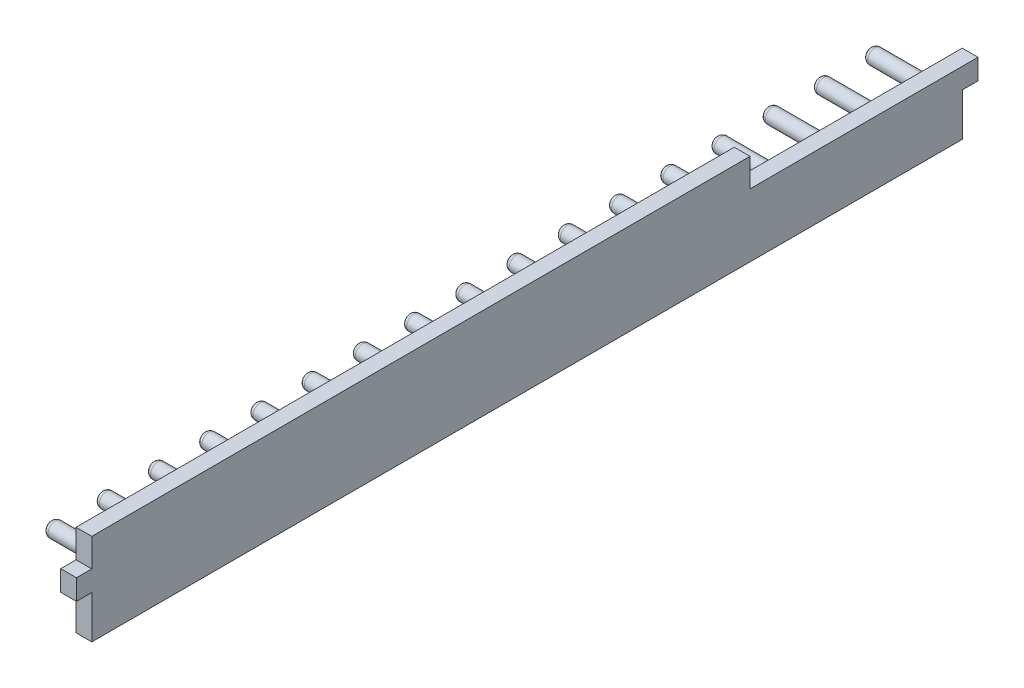
from build123d import *

# Parameters (mm, degrees)
BOSS_EXTRUDE1_DEPTH = 340
SKETCH2_R           = 2.9
BOSS_EXTRUDE2_DEPTH = 20
SKETCH4_R           = 2.9
BOSS_EXTRUDE3_DEPTH = 20
BOSS_EXTRUDE4_DEPTH = 340
SKETCH7_W           = 6.152414984
SKETCH7_H           = 8
BOSS_EXTRUDE5_DEPTH = 6
FILLET2_R           = 2
FILLET3_R           = 2
SKETCH9_W           = 83
SKETCH9_H           = 11
CUT_EXTRUDE3_DEPTH  = 27.152414984


with BuildPart() as part:
    # Sketch1 → Boss-Extrude1 (new body)
    with BuildSketch(Plane.XY):
        Polygon((0, 7.95), (2.04, 7.95), (6.152414984, 4.048), (6.152414984, -4.048), (2.04, -7.95), (0, -7.95), align=None)
    extrude(amount=BOSS_EXTRUDE1_DEPTH)

    # Sketch2 → Boss-Extrude2 (add)
    with BuildSketch(Plane.ZY):
        with Locations((10, 0)):
            Circle(SKETCH2_R)
        with Locations((30, 0)):
            Circle(SKETCH2_R)
        with Locations((50, 0)):
            Circle(SKETCH2_R)
        with Locations((70, 0)):
            Circle(SKETCH2_R)
        with Locations((90, 0)):
            Circle(SKETCH2_R)
        with Locations((110, 0)):
            Circle(SKETCH2_R)
        with Locations((130, 0)):
            Circle(SKETCH2_R)
        with Locations((150, 0)):
            Circle(SKETCH2_R)
        with Locations((170, 0)):
            Circle(SKETCH2_R)
        with Locations((190, 0)):
            Circle(SKETCH2_R)
        with Locations((210, 0)):
            Circle(SKETCH2_R)
        with Locations((230, 0)):
            Circle(SKETCH2_R)
        with Locations((250, 0)):
            Circle(SKETCH2_R)
    extrude(amount=BOSS_EXTRUDE2_DEPTH)

    # Sketch4 → Boss-Extrude3 (add)
    with BuildSketch(Plane.ZY):
        with Locations((270, 0)):
            Circle(SKETCH4_R)
        with Locations((290, 0)):
            Circle(SKETCH4_R)
        with Locations((310, 0)):
            Circle(SKETCH4_R)
        with Locations((330, 0)):
            Circle(SKETCH4_R)
    extrude(amount=BOSS_EXTRUDE3_DEPTH)

    # Sketch5 → Boss-Extrude4 (add)
    with BuildSketch(Plane.XY.offset(340)):
        Polygon((0, -7.95), (0, -20.95), (6.152414984, -20.95), (6.152414984, -4.048), (2.04, -7.95), align=None)
        Polygon((0, 7.95), (0, 14.75), (6.152414984, 14.75), (6.152414984, 4.048), (2.04, 7.95), align=None)
    extrude(amount=-BOSS_EXTRUDE4_DEPTH)

    # Sketch7 → Boss-Extrude5 (add)
    with BuildSketch(Plane.XY.offset(340)):
        with Locations((3.076207492, -0.25)):
            Rectangle(SKETCH7_W, SKETCH7_H)
    boss_extrude5 = extrude(amount=BOSS_EXTRUDE5_DEPTH)

    # Mirror1: Boss-Extrude5 across plane
    add(boss_extrude5.mirror(Plane.XY.offset(170)))

    # Fillet2
    fillet2_edges = [part.edges().sort_by_distance(p)[0] for p in [
        (-20, 0, 27.1),
        (-20, 0, 7.1),
        (-20, 0, 47.1),
        (-20, 0, 67.1),
        (-20, 0, 87.1),
        (-20, 0, 107.1),
        (-20, 0, 127.1),
        (-20, 0, 147.1),
        (-20, 0, 167.1),
        (-20, 0, 187.1),
        (-20, 0, 207.1),
        (-20, 0, 227.1),
        (-20, 0, 247.1),
    ]]
    fillet(fillet2_edges, radius=FILLET2_R)

    # Fillet3
    fillet3_edges = [part.edges().sort_by_distance(p)[0] for p in [
        (-20, 0, 267.1),
        (-20, 0, 287.1),
        (-20, 0, 307.1),
        (-20, 0, 327.1),
    ]]
    fillet(fillet3_edges, radius=FILLET3_R)

    # Sketch9 → Cut-Extrude3 (cut, through all)
    with BuildSketch(Plane(origin=(6.152414984, 0, 0), x_dir=(0, 0, -1), z_dir=(1, 0, 0))):
        with Locations((-41.5, 9.25)):
            Rectangle(SKETCH9_W, SKETCH9_H)
    extrude(amount=-CUT_EXTRUDE3_DEPTH, mode=Mode.SUBTRACT)


solid = part.part
